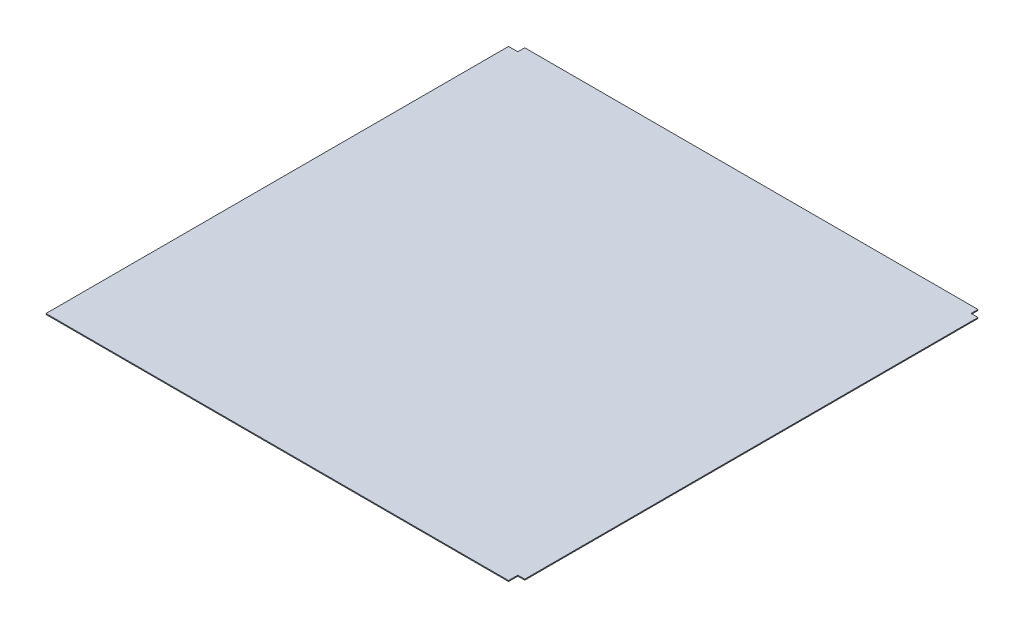
from build123d import *

# Parameters (mm, degrees)
RESSALTO_EXTRUS_O1_DEPTH = 1


with BuildPart() as part:
    # Esboço1 → Ressalto-extrusão1 (new body, symmetric)
    with BuildSketch(Plane(origin=(0, 0, 0), x_dir=(1, 0, 0), z_dir=(0, 1, 0))):
        Polygon((-487.5, 507.5), (492.5, 507.5), (492.5, 492.5), (507.5, 492.5), (507.5, -487.5), (492.5, -487.5), (492.5, -507.5), (-507.5, -507.5), (-507.5, 492.5), (-487.5, 492.5), align=None)
    extrude(amount=RESSALTO_EXTRUS_O1_DEPTH, both=True)


solid = part.part
